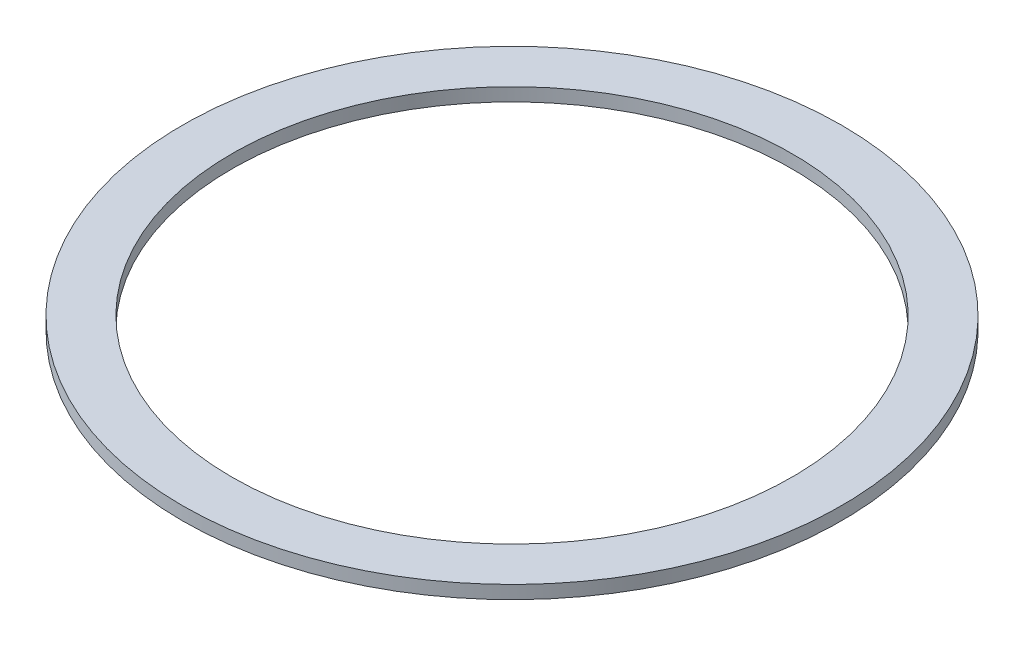
from build123d import *

# Parameters (mm, degrees)
ESBO_O1_R                = 100
ESBO_O1_R_2              = 85
RESSALTO_EXTRUS_O1_DEPTH = 4


with BuildPart() as part:
    # Esboço1 → Ressalto-extrusão1 (new body)
    with BuildSketch(Plane(origin=(0, 0, 0), x_dir=(1, 0, 0), z_dir=(0, 1, 0))):
        Circle(ESBO_O1_R)
        Circle(ESBO_O1_R_2, mode=Mode.SUBTRACT)
    extrude(amount=RESSALTO_EXTRUS_O1_DEPTH)


solid = part.part
